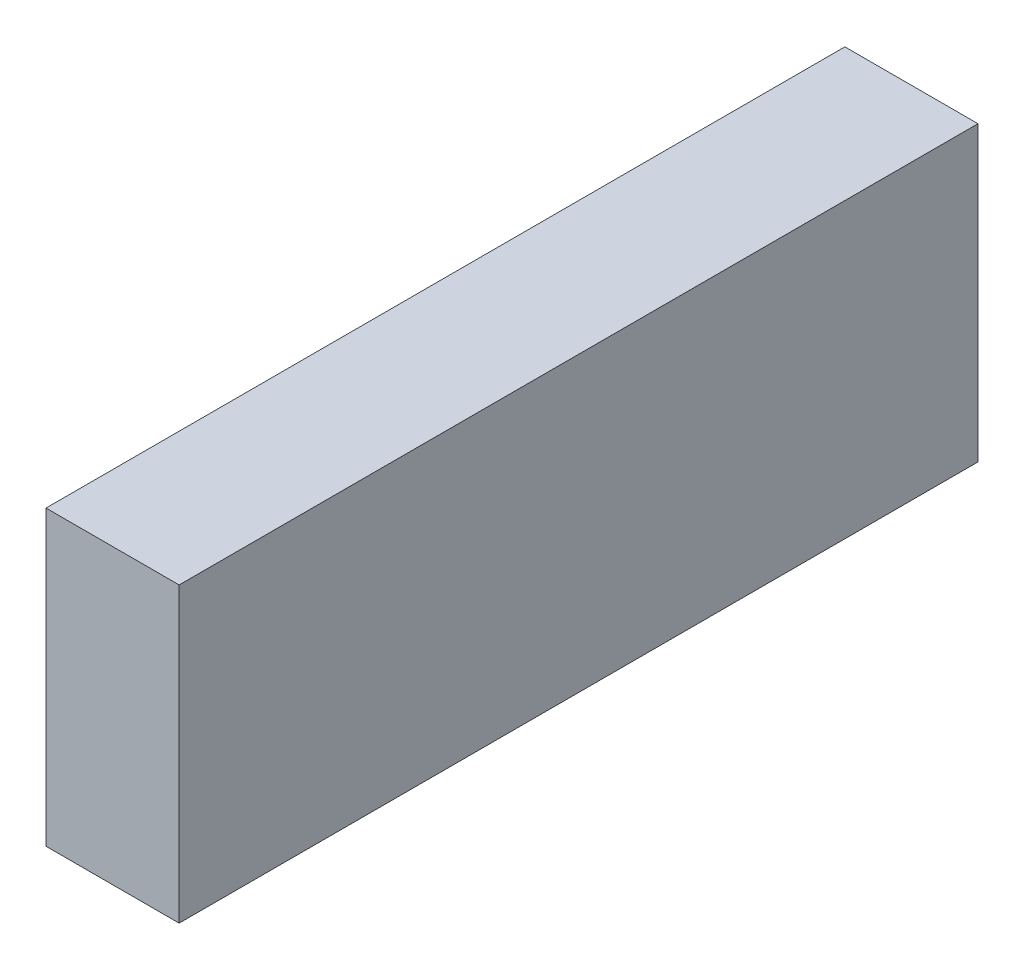
from build123d import *

# Parameters (mm, degrees)
SKETCH1_W           = 38.1
SKETCH1_H           = 13.97
BOSS_EXTRUDE1_DEPTH = 6.35


with BuildPart() as part:
    # Sketch1 → Boss-Extrude1 (new body)
    with BuildSketch(Plane(origin=(0, 0, 0), x_dir=(0, 0, -1), z_dir=(1, 0, 0))):
        Rectangle(SKETCH1_W, SKETCH1_H)
    extrude(amount=BOSS_EXTRUDE1_DEPTH)


solid = part.part
